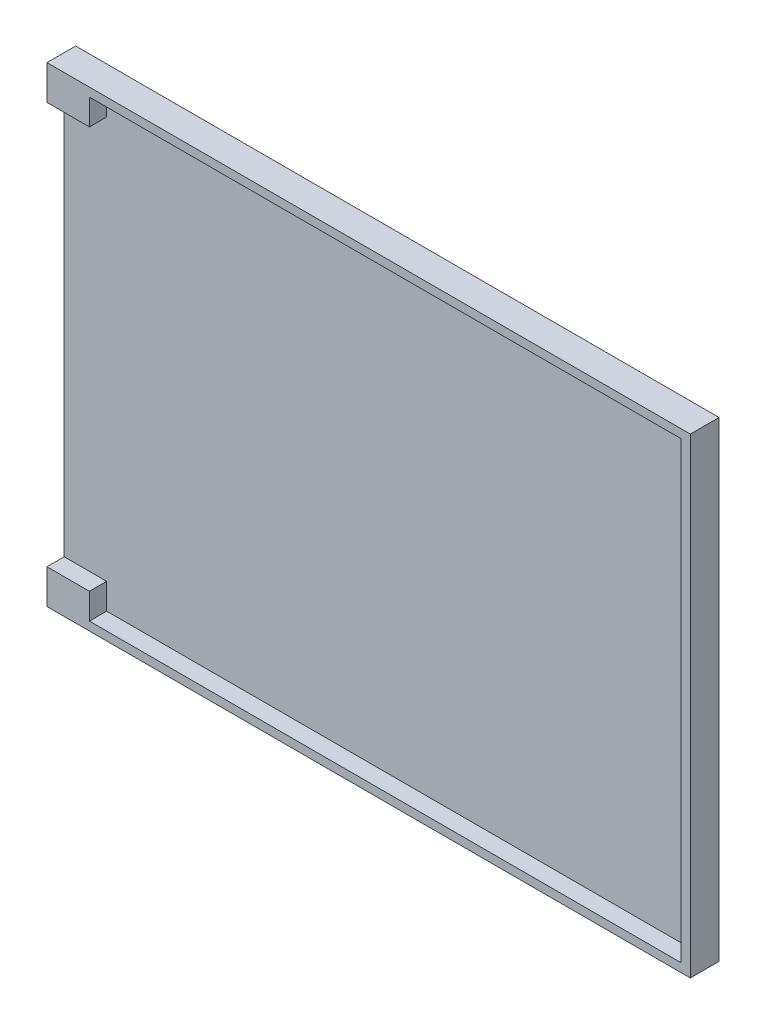
from build123d import *

# Parameters (mm, degrees)
SKETCH1_W           = 56
SKETCH1_H           = 41
BOSS_EXTRUDE1_DEPTH = 2.5
SKETCH2_W           = 51.5
SKETCH2_H           = 39.5
CUT_EXTRUDE1_DEPTH  = 1.5
SKETCH3_W           = 3.7
SKETCH3_H           = 35
CUT_EXTRUDE2_DEPTH  = 1.5


with BuildPart() as part:
    # Sketch1 → Boss-Extrude1 (new body)
    with BuildSketch(Plane.XY):
        with Locations((0.145813854, -9.904151416)):
            Rectangle(SKETCH1_W, SKETCH1_H)
    extrude(amount=BOSS_EXTRUDE1_DEPTH)

    # Sketch2 → Cut-Extrude1 (cut)
    with BuildSketch(Plane.XY.offset(2.5)):
        with Locations((1.595813854, -9.904151416)):
            Rectangle(SKETCH2_W, SKETCH2_H)
    extrude(amount=-CUT_EXTRUDE1_DEPTH, mode=Mode.SUBTRACT)

    # Sketch3 → Cut-Extrude2 (cut)
    with BuildSketch(Plane.XY.offset(2.5)):
        with Locations((-26.004186146, -9.904151416)):
            Rectangle(SKETCH3_W, SKETCH3_H)
    extrude(amount=-CUT_EXTRUDE2_DEPTH, mode=Mode.SUBTRACT)


solid = part.part
